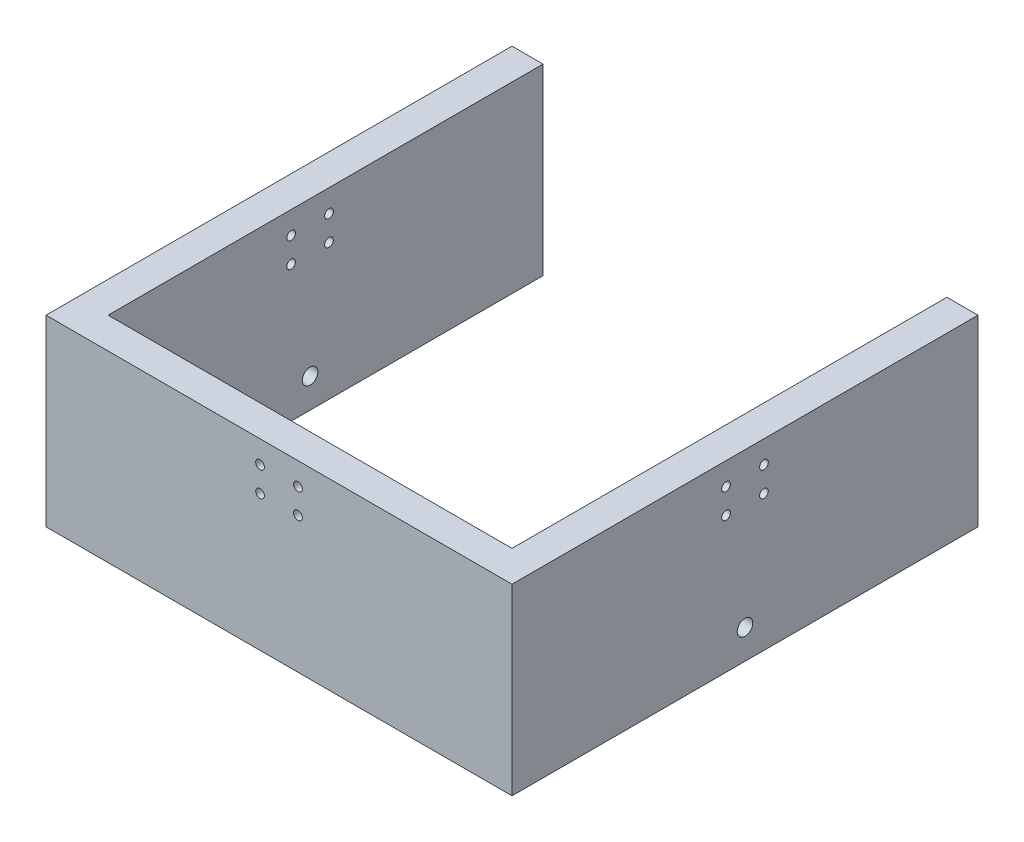
from build123d import *

# Parameters (mm, degrees)
SKETCH1_W           = 150
SKETCH1_H           = 150
BOSS_EXTRUDE1_DEPTH = 59
SKETCH2_W           = 130
SKETCH2_H           = 130
CUT_EXTRUDE1_DEPTH  = 122.371331047
SKETCH9_R           = 1.4
CUT_EXTRUDE4_DEPTH  = 10
CIRPATTERN1_COUNT   = 3
CIRPATTERN1_ANGLE   = 180
SKETCH10_W          = 130
SKETCH10_H          = 96.398295943
CUT_EXTRUDE6_DEPTH  = 122.371331047
SKETCH11_R          = 2.5
CUT_EXTRUDE7_DEPTH  = 178.780763864


with BuildPart() as part:
    # Sketch1 → Boss-Extrude1 (new body)
    with BuildSketch(Plane(origin=(0, 0, 0), x_dir=(1, 0, 0), z_dir=(0, 1, 0))):
        Rectangle(SKETCH1_W, SKETCH1_H)
    extrude(amount=-BOSS_EXTRUDE1_DEPTH)

    # Sketch2 → Cut-Extrude1 (cut, through all)
    with BuildSketch(Plane(origin=(0, 0, 0), x_dir=(1, 0, 0), z_dir=(0, 1, 0))):
        Rectangle(SKETCH2_W, SKETCH2_H)
    extrude(amount=-CUT_EXTRUDE1_DEPTH, mode=Mode.SUBTRACT)

    # Sketch9 → Cut-Extrude4 (cut)
    with BuildSketch(Plane.ZY.offset(75)):
        with Locations((-6.1, -7.25)):
            Circle(SKETCH9_R)
        with Locations((6.1, -7.25)):
            Circle(SKETCH9_R)
        with Locations((6.1, -15.25)):
            Circle(SKETCH9_R)
        with Locations((-6.1, -15.25)):
            Circle(SKETCH9_R)
    cut_extrude4 = extrude(amount=-CUT_EXTRUDE4_DEPTH, mode=Mode.SUBTRACT)

    # CirPattern1: Cut-Extrude4 ×3 about axis
    cirpattern1_axis = Axis((0, 0, 0), (0, 1, 0))
    for i in range(1, CIRPATTERN1_COUNT):
        add(cut_extrude4.rotate(cirpattern1_axis, i * CIRPATTERN1_ANGLE / (CIRPATTERN1_COUNT - 1)), mode=Mode.SUBTRACT)

    # Sketch10 → Cut-Extrude6 (cut, through all)
    with BuildSketch(Plane(origin=(0, 0, 0), x_dir=(1, 0, 0), z_dir=(0, 1, 0))):
        with Locations((0, 113.199147972)):
            Rectangle(SKETCH10_W, SKETCH10_H)
    extrude(amount=-CUT_EXTRUDE6_DEPTH, mode=Mode.SUBTRACT)

    # Sketch11 → Cut-Extrude7 (cut, through all)
    with BuildSketch(Plane(origin=(75, 0, 0), x_dir=(0, 0, -1), z_dir=(1, 0, 0))):
        with Locations((0, -49.5)):
            Circle(SKETCH11_R)
    extrude(amount=-CUT_EXTRUDE7_DEPTH, mode=Mode.SUBTRACT)


solid = part.part
